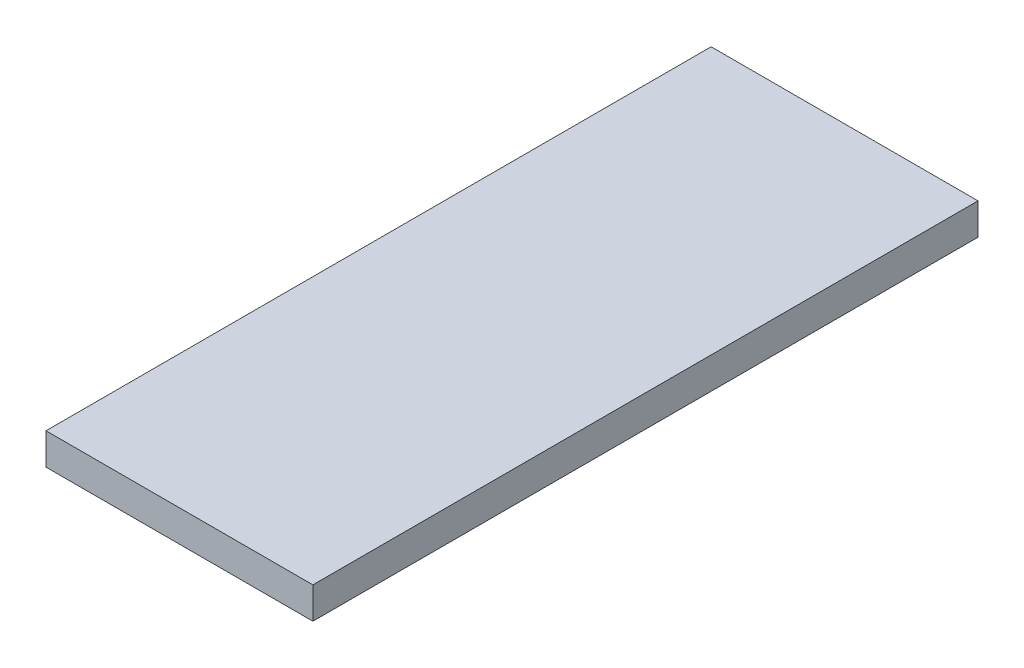
from build123d import *

# Parameters (mm, degrees)
SKETCH1_W           = 25.4
SKETCH1_H           = 63.3
BOSS_EXTRUDE1_DEPTH = 3


with BuildPart() as part:
    # Sketch1 → Boss-Extrude1 (new body)
    with BuildSketch(Plane(origin=(0, 0, 0), x_dir=(1, 0, 0), z_dir=(0, 1, 0))):
        Rectangle(SKETCH1_W, SKETCH1_H)
    extrude(amount=BOSS_EXTRUDE1_DEPTH)


solid = part.part
